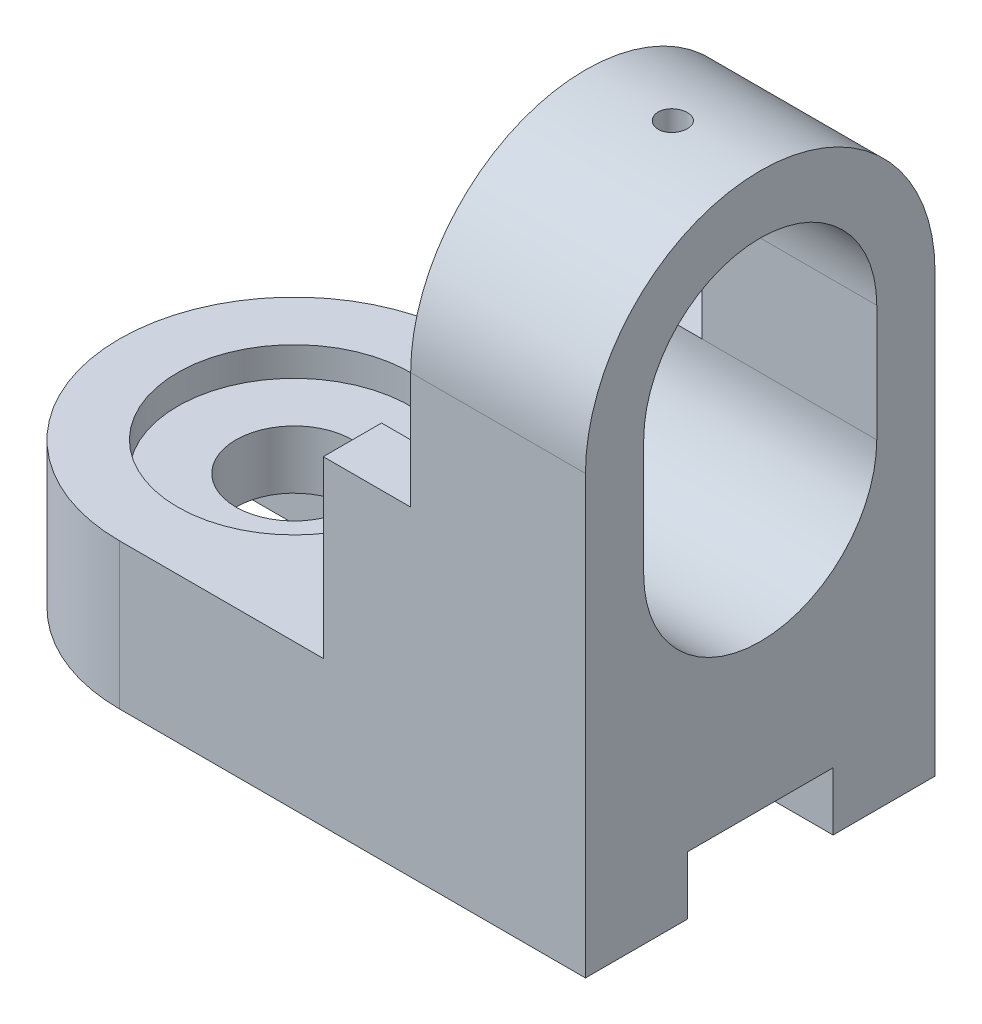
from build123d import *

# Parameters (mm, degrees)
SKETCH1_R               = 10
BOSS_EXTRUDE1_DEPTH     = 25
BOSS_EXTRUDE2_DEPTH     = 45
SKETCH4_W               = 110
SKETCH4_H               = 10
CUT_EXTRUDE1_DEPTH      = 12.5
SKETCH5_W               = 15
SKETCH5_H               = 50
CUT_EXTRUDE2_DEPTH      = 32.5
SKETCH6_W               = 10
SKETCH6_H               = 30
CUT_EXTRUDE3_DEPTH      = 65
CUT_EXTRUDE3_DEPTH_BACK = 30
SKETCH7_R               = 20
CUT_EXTRUDE4_DEPTH      = 5
SKETCH9_R               = 2.5
CUT_EXTRUDE5_DEPTH      = 55


with BuildPart() as part:
    # Sketch1 → Boss-Extrude1 (new body)
    with BuildSketch(Plane(origin=(0, 0, 0), x_dir=(1, 0, 0), z_dir=(0, 1, 0))):
        with BuildLine():
            Line((0, -30), (80, -30))
            Line((80, -30), (80, 30))
            Line((80, 30), (0, 30))
            ThreePointArc((0, 30), (-30, 0), (0, -30))
        make_face()
        Circle(SKETCH1_R, mode=Mode.SUBTRACT)
    extrude(amount=BOSS_EXTRUDE1_DEPTH)

    # Sketch2 → Boss-Extrude2 (add)
    with BuildSketch(Plane(origin=(80, 0, 0), x_dir=(0, 0, -1), z_dir=(1, 0, 0))):
        with BuildLine():
            Line((-30, 25), (30, 25))
            Line((30, 25), (30, 75))
            Line((30, 75), (20, 75))
            Line((20, 75), (20, 55))
            ThreePointArc((20, 55), (0, 35), (-20, 55))
            Line((-20, 55), (-20, 75))
            Line((-20, 75), (-30, 75))
            Line((-30, 75), (-30, 25))
        make_face()
        with BuildLine():
            Line((20, 75), (30, 75))
            ThreePointArc((30, 75), (0, 105), (-30, 75))
            Line((-30, 75), (-20, 75))
            ThreePointArc((-20, 75), (-17.020295968, 85.502834149), (-8.969047485, 92.876134572))
            ThreePointArc((-8.969047485, 92.876134572), (2.405486487, 94.854813894), (12.978420983, 90.217114995))
            ThreePointArc((12.978420983, 90.217114995), (18.159961724, 83.379486271), (20, 75))
        make_face()
    extrude(amount=-BOSS_EXTRUDE2_DEPTH)

    # Sketch4 → Cut-Extrude1 (cut, symmetric)
    with BuildSketch(Plane.XY):
        with Locations((25, 5)):
            Rectangle(SKETCH4_W, SKETCH4_H)
    extrude(amount=CUT_EXTRUDE1_DEPTH, both=True, mode=Mode.SUBTRACT)

    # Sketch5 → Cut-Extrude2 (cut, symmetric)
    with BuildSketch(Plane.XY):
        with Locations((42.5, 80)):
            Rectangle(SKETCH5_W, SKETCH5_H)
    extrude(amount=CUT_EXTRUDE2_DEPTH, both=True, mode=Mode.SUBTRACT)

    # Sketch6 → Cut-Extrude3 (cut, two sides)
    with BuildSketch(Plane(origin=(0, 55, 0), x_dir=(1, 0, 0), z_dir=(0, 1, 0))) as cut_extrude3_sk:
        with Locations((40, 0)):
            Rectangle(SKETCH6_W, SKETCH6_H)
    extrude(amount=CUT_EXTRUDE3_DEPTH, mode=Mode.SUBTRACT)
    extrude(cut_extrude3_sk.sketch, amount=-CUT_EXTRUDE3_DEPTH_BACK, mode=Mode.SUBTRACT)

    # Sketch7 → Cut-Extrude4 (cut)
    with BuildSketch(Plane(origin=(0, 25, 0), x_dir=(1, 0, 0), z_dir=(0, 1, 0))):
        Circle(SKETCH7_R)
    extrude(amount=-CUT_EXTRUDE4_DEPTH, mode=Mode.SUBTRACT)

    # Sketch9 → Cut-Extrude5 (cut)
    with BuildSketch(Plane(origin=(0, 55, 0), x_dir=(1, 0, 0), z_dir=(0, 1, 0))):
        with Locations((65, 0)):
            Circle(SKETCH9_R)
    extrude(amount=CUT_EXTRUDE5_DEPTH, mode=Mode.SUBTRACT)


solid = part.part
